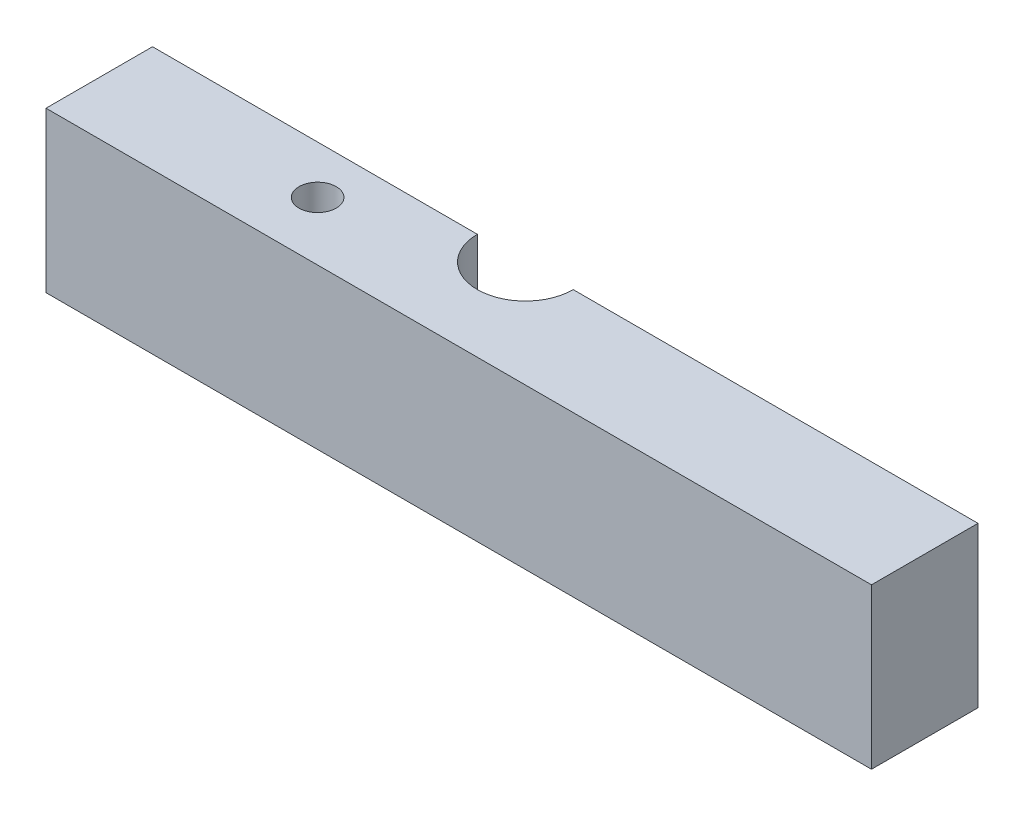
from build123d import *

# Parameters (mm, degrees)
SKETCH1_W           = 155
SKETCH1_H           = 40
SKETCH1_R           = 9
BOSS_EXTRUDE1_DEPTH = 30
SKETCH2_W           = 155
SKETCH2_H           = 30
CUT_EXTRUDE1_DEPTH  = 21
SKETCH4_R           = 3.5
CUT_EXTRUDE3_DEPTH  = 31


with BuildPart() as part:
    # Sketch1 → Boss-Extrude1 (new body)
    with BuildSketch(Plane(origin=(0, 0, 0), x_dir=(1, 0, 0), z_dir=(0, 1, 0))):
        with Locations((7.5, 0)):
            Rectangle(SKETCH1_W, SKETCH1_H)
        Circle(SKETCH1_R, mode=Mode.SUBTRACT)
    extrude(amount=BOSS_EXTRUDE1_DEPTH)

    # Sketch2 → Cut-Extrude1 (cut, through all)
    with BuildSketch(Plane.XY):
        with Locations((7.5, 15)):
            Rectangle(SKETCH2_W, SKETCH2_H)
    extrude(amount=-CUT_EXTRUDE1_DEPTH, mode=Mode.SUBTRACT)

    # Sketch4 → Cut-Extrude3 (cut, through all)
    with BuildSketch(Plane.XZ):
        with Locations((-30, 9)):
            Circle(SKETCH4_R)
    extrude(amount=-CUT_EXTRUDE3_DEPTH, mode=Mode.SUBTRACT)


solid = part.part
